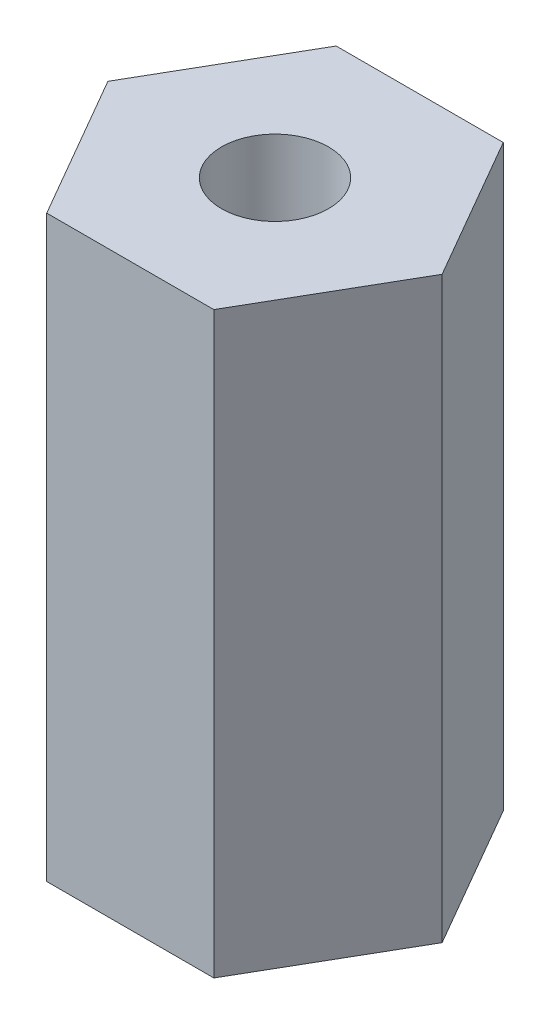
from build123d import *

# Parameters (mm, degrees)
BOSS_EXTRUDE1_DEPTH = 50.8
SKETCH2_R           = 4.699
CUT_EXTRUDE1_DEPTH  = 50.8


with BuildPart() as part:
    # Sketch1 → Boss-Extrude1 (new body)
    with BuildSketch(Plane(origin=(0, 0, 0), x_dir=(1, 0, 0), z_dir=(0, 1, 0))):
        Polygon((14.664696837, 0), (7.332348419, 12.7), (-7.332348419, 12.7), (-14.664696837, 0), (-7.332348419, -12.7), (7.332348419, -12.7), align=None)
    extrude(amount=BOSS_EXTRUDE1_DEPTH)

    # Sketch2 → Cut-Extrude1 (cut)
    with BuildSketch(Plane.XZ):
        Circle(SKETCH2_R)
    extrude(amount=-CUT_EXTRUDE1_DEPTH, mode=Mode.SUBTRACT)


solid = part.part
